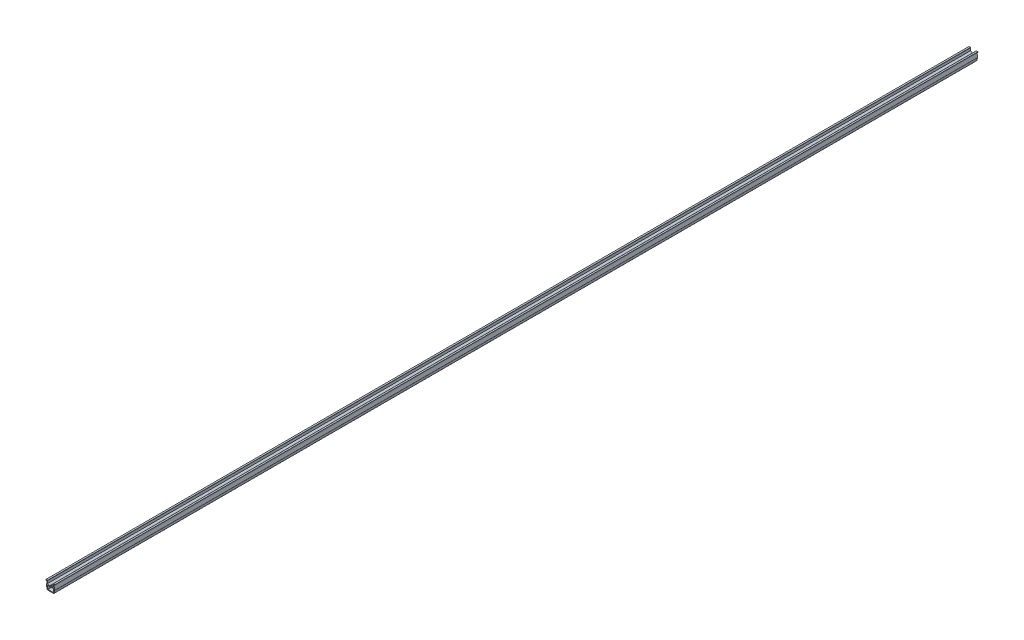
from build123d import *

# Parameters (mm, degrees)
EXTRUDE_1_DEPTH = 1000


with BuildPart() as part:
    # 草图1 → 拉伸1 (new body)
    with BuildSketch(Plane.XY):
        with BuildLine():
            Line((1.043839833, 81.14029792), (1.043839833, 80.34029792))
            Line((1.043839833, 80.34029792), (2.044943692, 80.34029792))
            Line((2.044943692, 80.34029792), (1.664500386, 75.324244599))
            ThreePointArc((1.664500386, 75.324244599), (1.662291386, 75.248793926), (1.671465549, 75.173870508))
            Line((1.671465549, 75.173870508), (2.238017918, 72.341108665))
            ThreePointArc((2.238017918, 72.341108665), (2.411313803, 72.052495662), (2.728308256, 71.939166732))
            Line((2.728308256, 71.939166732), (9.180582792, 71.939166732))
            ThreePointArc((9.180582792, 71.939166732), (9.497577245, 72.052495662), (9.67087313, 72.341108665))
            Line((9.67087313, 72.341108665), (10.237425499, 75.173870508))
            ThreePointArc((10.237425499, 75.173870508), (10.246599662, 75.248793926), (10.244390662, 75.324244599))
            Line((10.244390662, 75.324244599), (9.863947356, 80.34029792))
            Line((9.863947356, 80.34029792), (10.843839833, 80.34029792))
            Line((10.843839833, 80.34029792), (10.843839833, 81.14029792))
            Line((10.843839833, 81.14029792), (9.187027507, 81.14029792))
            ThreePointArc((9.187027507, 81.14029792), (9.038391573, 81.074116301), (8.988125307, 80.919371511))
            Line((8.988125307, 80.919371511), (9.145554921, 78.023027985))
            Line((9.145554921, 78.023027985), (7.143839833, 76.86733724))
            ThreePointArc((7.143839833, 76.86733724), (6.997429672, 76.720927079), (6.943839833, 76.520927079))
            ThreePointArc((6.943839833, 76.520927079), (7.143839833, 76.174516917), (7.543839833, 76.174516917))
            Line((7.543839833, 76.174516917), (9.237177898, 77.152166105))
            Line((9.237177898, 77.152166105), (9.425432977, 75.362831424))
            ThreePointArc((9.425432977, 75.362831424), (9.427641976, 75.287380751), (9.418467813, 75.212457334))
            Line((9.418467813, 75.212457334), (9.004424317, 73.142239853))
            ThreePointArc((9.004424317, 73.142239853), (8.831128432, 72.85362685), (8.514133979, 72.74029792))
            Line((8.514133979, 72.74029792), (3.373545687, 72.74029792))
            ThreePointArc((3.373545687, 72.74029792), (3.056551234, 72.85362685), (2.883255349, 73.142239853))
            Line((2.883255349, 73.142239853), (2.469211853, 75.212457334))
            ThreePointArc((2.469211853, 75.212457334), (2.46003769, 75.287380751), (2.462246689, 75.362831424))
            Line((2.462246689, 75.362831424), (2.650501768, 77.152166105))
            Line((2.650501768, 77.152166105), (4.343839833, 76.174516917))
            ThreePointArc((4.343839833, 76.174516917), (4.743839833, 76.174516917), (4.943839833, 76.520927079))
            ThreePointArc((4.943839833, 76.520927079), (4.890249995, 76.720927079), (4.743839833, 76.86733724))
            Line((4.743839833, 76.86733724), (2.742124745, 78.023027985))
            Line((2.742124745, 78.023027985), (2.899554359, 80.919371511))
            ThreePointArc((2.899554359, 80.919371511), (2.849288093, 81.074116301), (2.700652159, 81.14029792))
            Line((2.700652159, 81.14029792), (1.043839833, 81.14029792))
        make_face()
    extrude(amount=EXTRUDE_1_DEPTH)


solid = part.part
